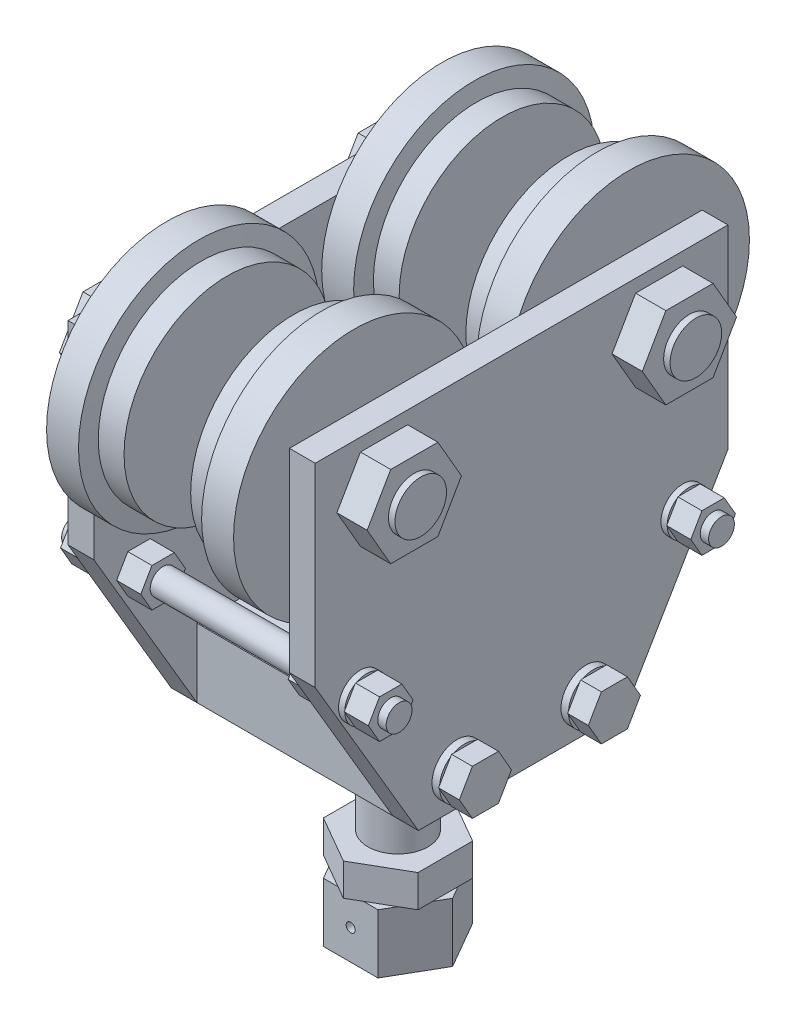
from build123d import *

# Parameters (mm, degrees)
YOKE_CROSS_SECTION_W           = 152.4
YOKE_CROSS_SECTION_H           = 50.8
YOKE_DEPTH                     = 72.23125
SIDEPLATE_DEPTH                = 19.05
WHEEL_PIN_NUT_DEPTH            = 22.352
WHEEL_PIN_PROJECTION_PROFILE_R = 19.05
WHEEL_PIN_PROJECTION_DEPTH     = 4.7625
LOCKNUTS_PROFILE_R             = 18.542
LOCKNUTS_DEPTH                 = 5.5626
SCREWS_DEPTH                   = 15.3416
PROFILE_R                      = 30.1625
KING_BOLT_HEAD_DEPTH           = 38.1
DIA_R                          = 22.225
KING_BOLT_DEPTH                = 83.052101
KING_BOLT_JAM_NUT_DEPTH        = 23.8125
KING_BOLT_NUT_DEPTH            = 43.6372
SKETCH5_R                      = 22.225
EXTENDED_KING_BOLT_DEPTH       = 9.525
CHAMFER1_SIZE                  = 2.38125
THREADED_START                 = -72.23125
SKETCH6_R                      = 9.525
THREADED_ROD_DEPTH             = 119.85625
THREADED_ROD_NUTS_INNER_DEPTH  = 17.8054
SKETCH8_R                      = 16.129
THREADED_ROD_LOCKWASHER_DEPTH  = 4.572
THREADED_ROD_NUT_OUTER_DEPTH   = 17.8054
MIRROR3_START                  = -72.23125
MIRROR3_COPY_1_SKETCH_R        = 9.525
MIRROR3_COPY_1_DEPTH           = 119.85625
MIRROR3_COPY_2_DEPTH           = 17.8054
MIRROR3_COPY_3_SKETCH_R        = 16.129
MIRROR3_COPY_3_DEPTH           = 4.572
MIRROR3_COPY_4_DEPTH           = 17.8054
SKETCH10_R                     = 3.3655
COTTER_PIN_HOLE_DEPTH          = 188.325
SKETCH12_R                     = 30.1625
SKETCH12_R_2                   = 25.4
SPACER_DEPTH                   = 12.7


with BuildPart() as part:
    # YOKE CROSS SECTION → YOKE (new body)
    with BuildSketch(Plane(origin=(0, 0, 0), x_dir=(0, 0, -1), z_dir=(1, 0, 0))):
        with Locations((0, 25.4)):
            Rectangle(YOKE_CROSS_SECTION_W, YOKE_CROSS_SECTION_H)
    extrude(amount=YOKE_DEPTH)

    # SIDEPLATE PROFILE → SIDEPLATE (add)
    with BuildSketch(Plane(origin=(72.23125, 0, 0), x_dir=(0, 0, -1), z_dir=(1, 0, 0))):
        Polygon((-152.4, 273.05), (152.4, 273.05), (152.4, 129.54), (76.2, 0), (0, 0), (-76.2, 0), (-152.4, 129.54), align=None)
    extrude(amount=SIDEPLATE_DEPTH)

    # WHEEL PIN NUT PROFILE → WHEEL PIN NUT (add)
    with BuildSketch(Plane(origin=(91.28125, 0, 0), x_dir=(0, 0, -1), z_dir=(1, 0, 0))):
        Polygon((-66.771345011, 233.3625), (-84.185672506, 263.525), (-119.014327494, 263.525), (-136.428654989, 233.3625), (-119.014327494, 203.2), (-84.185672506, 203.2), align=None)
    wheel_pin_nut = extrude(amount=WHEEL_PIN_NUT_DEPTH)

    # WHEEL PIN PROJECTION PROFILE → WHEEL PIN PROJECTION (add)
    with BuildSketch(Plane(origin=(113.63325, 0, 0), x_dir=(0, 0, -1), z_dir=(1, 0, 0))):
        with Locations((-101.6, 233.3625)):
            Circle(WHEEL_PIN_PROJECTION_PROFILE_R)
    wheel_pin_projection = extrude(amount=WHEEL_PIN_PROJECTION_DEPTH)

    # LOCKNUTS PROFILE → LOCKNUTS (add)
    with BuildSketch(Plane(origin=(91.28125, 0, 0), x_dir=(0, 0, -1), z_dir=(1, 0, 0))):
        with Locations((-47.625, 25.4)):
            Circle(LOCKNUTS_PROFILE_R)
    locknuts = extrude(amount=LOCKNUTS_DEPTH)

    # SCREWS PROFILE → SCREWS (add)
    with BuildSketch(Plane(origin=(96.84385, 0, 0), x_dir=(0, 0, -1), z_dir=(1, 0, 0))):
        Polygon((-28.377585401, 25.4), (-38.0012927, 42.06875), (-57.2487073, 42.06875), (-66.872414599, 25.4), (-57.2487073, 8.73125), (-38.0012927, 8.73125), align=None)
    screws = extrude(amount=SCREWS_DEPTH)

    # PROFILE → KING BOLT HEAD (add)
    with BuildSketch(Plane(origin=(0, 50.8, 0), x_dir=(-1, 0, 0), z_dir=(0, 1, 0))):
        with Locations(Location((0, 0, 0), (0, 0, 90))):  # turned: the seam where the file's is
            Circle(PROFILE_R)
    extrude(amount=KING_BOLT_HEAD_DEPTH)

    # Mirror1: WHEEL PIN NUT, WHEEL PIN PROJECTION across plane
    add(wheel_pin_nut.mirror(Plane.XY))
    add(wheel_pin_projection.mirror(Plane.XY))

    # Mirror YOKE SCREWS: LOCKNUTS, SCREWS across plane
    add(locknuts.mirror(Plane.XY))
    add(screws.mirror(Plane.XY))

    # Mirror SIDE 1: part across plane


with BuildPart() as part_1:
    add(part.part)
    add(part.part.mirror(Plane(origin=(0, 0, 0), x_dir=(0, 0, 1), z_dir=(1, 0, 0))))

    # DIA. → KING BOLT (add)
    with BuildSketch(Plane.XZ):
        with Locations(Location((0, 0, 0), (0, 0, 90))):  # turned: the seam where the file's is
            Circle(DIA_R)
    extrude(amount=KING_BOLT_DEPTH)

    # KING BOLT JAN NUT PROFILE → KING BOLT JAM NUT (add)
    with BuildSketch(Plane.XZ.offset(83.052100888)):
        Polygon((0, -40.327916303), (34.925, -20.163958151), (34.925, 20.163958151), (0, 40.327916303), (-34.925, 20.163958151), (-34.925, -20.163958151), align=None)
    extrude(amount=KING_BOLT_JAM_NUT_DEPTH)

    # KING BOLT NUT PROFILE → KING BOLT NUT (add)
    with BuildSketch(Plane.XZ.offset(106.864600888)):
        Polygon((40.327916303, 0), (20.163958151, 34.925), (-20.163958151, 34.925), (-40.327916303, 0), (-20.163958151, -34.925), (20.163958151, -34.925), align=None)
    extrude(amount=KING_BOLT_NUT_DEPTH)

    # Sketch5 → EXTENDED KING BOLT (add)
    with BuildSketch(Plane.XZ.offset(150.501800888)):
        with Locations(Location((0, 0, 0), (0, 0, 90))):  # turned: the seam where the file's is
            Circle(SKETCH5_R)
    extrude(amount=EXTENDED_KING_BOLT_DEPTH)

    # Chamfer1
    chamfer1_edges = [part_1.edges().sort_by_distance(p)[0] for p in [
        (0, -160.026800888, -22.225),
    ]]
    chamfer(chamfer1_edges, length=CHAMFER1_SIZE)

    # Sketch6 → THREADED ROD (add)
    with BuildSketch(Plane(origin=(72.23125, 0, 0), x_dir=(0, 0, -1), z_dir=(1, 0, 0)).offset(THREADED_START)):
        with Locations((-119.0625, 107.95)):
            Circle(SKETCH6_R)
    threaded_rod = extrude(amount=THREADED_ROD_DEPTH)

    # Sketch7 → THREADED ROD NUTS INNER (add)
    with BuildSketch(Plane(origin=(72.23125, 0, 0), x_dir=(0, 0, -1), z_dir=(1, 0, 0))):
        Polygon((-102.564716058, 107.95), (-110.813608029, 122.2375), (-127.311391971, 122.2375), (-135.560283942, 107.95), (-127.311391971, 93.6625), (-110.813608029, 93.6625), align=None)
    threaded_rod_nuts_inner = extrude(amount=-THREADED_ROD_NUTS_INNER_DEPTH)

    # Sketch8 → THREADED ROD LOCKWASHER (add)
    with BuildSketch(Plane(origin=(91.28125, 0, 0), x_dir=(0, 0, -1), z_dir=(1, 0, 0))):
        with Locations((-119.0625, 107.95)):
            Circle(SKETCH8_R)
    threaded_rod_lockwasher = extrude(amount=THREADED_ROD_LOCKWASHER_DEPTH)

    # Sketch9 → THREADED ROD NUT OUTER (add)
    with BuildSketch(Plane(origin=(95.85325, 0, 0), x_dir=(0, 0, -1), z_dir=(1, 0, 0))):
        Polygon((-102.564716058, 107.95), (-110.813608029, 122.2375), (-127.311391971, 122.2375), (-135.560283942, 107.95), (-127.311391971, 93.6625), (-110.813608029, 93.6625), align=None)
    threaded_rod_nut_outer = extrude(amount=THREADED_ROD_NUT_OUTER_DEPTH)

    # Mirror2: THREADED ROD, THREADED ROD NUTS INNER, THREADED ROD LOCKWASHER, THREADED ROD NUT OUTER across plane
    add(threaded_rod.mirror(Plane.XY))
    add(threaded_rod_nuts_inner.mirror(Plane.XY))
    add(threaded_rod_lockwasher.mirror(Plane.XY))
    add(threaded_rod_nut_outer.mirror(Plane.XY))

    # Mirror3: THREADED ROD, THREADED ROD NUTS INNER, THREADED ROD LOCKWASHER, THREADED ROD NUT OUTER across plane
    add(threaded_rod.mirror(Plane(origin=(0, 0, 0), x_dir=(0, 0, 1), z_dir=(1, 0, 0))))
    add(threaded_rod_nuts_inner.mirror(Plane(origin=(0, 0, 0), x_dir=(0, 0, 1), z_dir=(1, 0, 0))))
    add(threaded_rod_lockwasher.mirror(Plane(origin=(0, 0, 0), x_dir=(0, 0, 1), z_dir=(1, 0, 0))))
    add(threaded_rod_nut_outer.mirror(Plane(origin=(0, 0, 0), x_dir=(0, 0, 1), z_dir=(1, 0, 0))))

    # Mirror3 copy 1 sketch → Mirror3 copy 1 (add)
    with BuildSketch(Plane.ZY.offset(72.23125).offset(MIRROR3_START)):
        with Locations((-119.0625, 107.95)):
            Circle(MIRROR3_COPY_1_SKETCH_R)
    extrude(amount=MIRROR3_COPY_1_DEPTH)

    # Mirror3 copy 2 sketch → Mirror3 copy 2 (add)
    with BuildSketch(Plane.ZY.offset(72.23125)):
        Polygon((-102.564716058, 107.95), (-110.813608029, 122.2375), (-127.311391971, 122.2375), (-135.560283942, 107.95), (-127.311391971, 93.6625), (-110.813608029, 93.6625), align=None)
    extrude(amount=-MIRROR3_COPY_2_DEPTH)

    # Mirror3 copy 3 sketch → Mirror3 copy 3 (add)
    with BuildSketch(Plane.ZY.offset(91.28125)):
        with Locations((-119.0625, 107.95)):
            Circle(MIRROR3_COPY_3_SKETCH_R)
    extrude(amount=MIRROR3_COPY_3_DEPTH)

    # Mirror3 copy 4 sketch → Mirror3 copy 4 (add)
    with BuildSketch(Plane.ZY.offset(95.85325)):
        Polygon((-102.564716058, 107.95), (-110.813608029, 122.2375), (-127.311391971, 122.2375), (-135.560283942, 107.95), (-127.311391971, 93.6625), (-110.813608029, 93.6625), align=None)
    extrude(amount=MIRROR3_COPY_4_DEPTH)

    # Sketch10 → COTTER PIN HOLE (cut, through all)
    with BuildSketch(Plane.XY.offset(34.925)):
        with Locations((0, -128.276800888)):
            Circle(SKETCH10_R)
    extrude(amount=-COTTER_PIN_HOLE_DEPTH, mode=Mode.SUBTRACT)

    # Sketch11 → WHEEL (revolve)
    with BuildSketch(Plane.XY.offset(101.6), mode=Mode.PRIVATE) as wheel_sk:
        Polygon((72.23125, 260.35), (72.23125, 233.3625), (24.606297625, 233.3625), (24.606297625, 309.490746707), (43.656278575, 309.490746707), (45.451231443, 322.2625), (69.056253175, 322.2625), (69.056253175, 260.35), align=None)
    wheel = revolve(wheel_sk.sketch.rotate(Axis((118.39575, 233.3625, 101.6), (-1, 0, 0)), 90), axis=Axis((118.39575, 233.3625, 101.6), (-1, 0, 0)))  # turned: the seam where the file's is

    # Mirror4: WHEEL across plane
    add(wheel.mirror(Plane.XY))

    # Mirror5: WHEEL across plane
    add(wheel.mirror(Plane(origin=(0, 0, 0), x_dir=(0, 0, 1), z_dir=(1, 0, 0))))

    # Mirror5 copy 1 sketch → Mirror5 copy 1 (revolve)
    with BuildSketch(Plane(origin=(0, 0, -101.6), x_dir=(-1, 0, 0), z_dir=(0, 0, -1))):
        Polygon((72.23125, 260.35), (72.23125, 233.3625), (24.606297625, 233.3625), (24.606297625, 309.490746707), (43.656278575, 309.490746707), (45.451231443, 322.2625), (69.056253175, 322.2625), (69.056253175, 260.35), align=None)
    revolve(axis=Axis((-118.39575, 233.3625, -101.6), (1, 0, 0)))

    # Sketch12 → SPACER (add)
    with BuildSketch(Plane.XZ):
        with Locations(Location((0, 0, 0), (0, 0, 90))):  # turned: the seam where the file's is
            Circle(SKETCH12_R)
        with Locations(Location((0, 0, 0), (0, 0, 270))):  # turned: the seam where the file's is
            Circle(SKETCH12_R_2, mode=Mode.SUBTRACT)
    extrude(amount=SPACER_DEPTH)


solid = part_1.part
